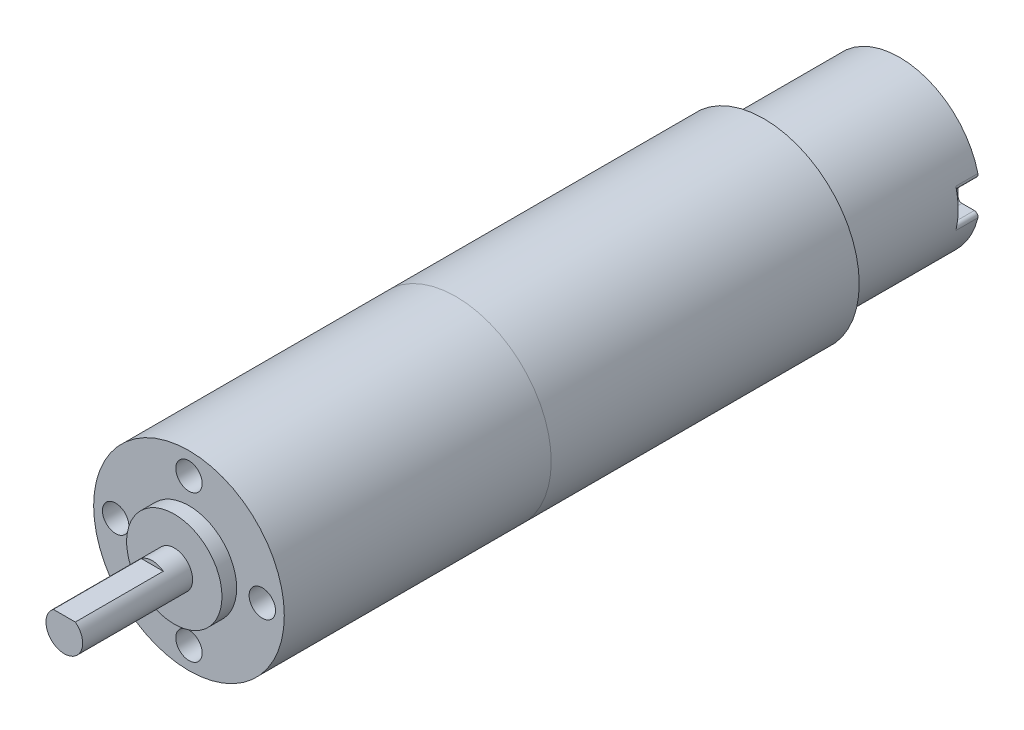
from build123d import *

# Parameters (mm, degrees)
ESQUISSE1_R                = 13
BOSS_EXTRU_REDUCTEUR_DEPTH = 36.4
ESQUISSE2_R                = 2.5
BOSS_EXTRU_ARBRE_DEPTH     = 17
ESQUISSE4_R                = 6.5
ESQUISSE4_R_2              = 2.5
BOSS_EXTRU_3_DEPTH         = 2
ESQUISSE5_R                = 1.8
ENL_V_MAT_EXTRU_2_DEPTH    = 4
ENL_V_START                = -12
ENL_V_MAT_EXTRU_3_DEPTH    = 12
ESQUISSE7_R                = 2.496805343
BOSS_EXTRU_4_DEPTH         = 3
ESQUISSE9_R                = 13
BOSS_EXTRU_5_DEPTH         = 42
ESQUISSE10_R               = 11
BOSS_EXTRU_6_DEPTH         = 18.5
ENL_V_MAT_EXTRU_5_DEPTH    = 4
ENL_V_MAT_EXTRU_6_DEPTH    = 3
CONG_1_R                   = 0.5


with BuildPart() as part:
    # Esquisse1 → Boss.-Extru. Reducteur (new body)
    with BuildSketch(Plane.XY):
        Circle(ESQUISSE1_R)
    extrude(amount=BOSS_EXTRU_REDUCTEUR_DEPTH)

    # Esquisse2 → Boss.-Extru. Arbre (add)
    with BuildSketch(Plane.XY.offset(36.4)):
        Circle(ESQUISSE2_R)
    extrude(amount=BOSS_EXTRU_ARBRE_DEPTH)

    # Esquisse4 → Boss.-Extru.3 (add)
    with BuildSketch(Plane.XY.offset(36.4)):
        Circle(ESQUISSE4_R)
        Circle(ESQUISSE4_R_2, mode=Mode.SUBTRACT)
    extrude(amount=BOSS_EXTRU_3_DEPTH)

    # Esquisse5 → Enl_v. mat.-Extru.2 (cut)
    with BuildSketch(Plane.XY.offset(36.4)):
        with Locations((0, 10)):
            Circle(ESQUISSE5_R)
        with Locations((-10, 0)):
            Circle(ESQUISSE5_R)
        with Locations((0, -10)):
            Circle(ESQUISSE5_R)
        with Locations((10, 0)):
            Circle(ESQUISSE5_R)
    extrude(amount=-ENL_V_MAT_EXTRU_2_DEPTH, mode=Mode.SUBTRACT)

    # Esquisse6 → Enl_v. mat.-Extru.3 (cut)
    with BuildSketch(Plane.XY.offset(53.4).offset(ENL_V_START)):
        with BuildLine():
            Line((0, 2), (1.5, 2))
            ThreePointArc((1.5, 2), (0, 2.5), (-1.5, 2))
            Line((-1.5, 2), (0, 2))
        make_face()
    extrude(amount=ENL_V_MAT_EXTRU_3_DEPTH, mode=Mode.SUBTRACT)


with BuildPart() as body_2:
    # Esquisse7 → Boss.-Extru.4 (new body)
    with BuildSketch(Plane.XY.offset(36.4)):
        Circle(ESQUISSE7_R)
    extrude(amount=BOSS_EXTRU_4_DEPTH)


with BuildPart() as body_3:
    # Esquisse9 → Boss.-Extru.5 (new body)
    with BuildSketch(Plane(origin=(0, 0, 0), x_dir=(-1, 0, 0), z_dir=(0, 0, -1))):
        Circle(ESQUISSE9_R)
    extrude(amount=BOSS_EXTRU_5_DEPTH)

    # Esquisse10 → Boss.-Extru.6 (add)
    with BuildSketch(Plane(origin=(0, 0, -42), x_dir=(-1, 0, 0), z_dir=(0, 0, -1))):
        Circle(ESQUISSE10_R)
    extrude(amount=BOSS_EXTRU_6_DEPTH)

    # Esquisse12 → Enl_v. mat.-Extru.5 (cut)
    with BuildSketch(Plane(origin=(0, 0, -60.5), x_dir=(-1, 0, 0), z_dir=(0, 0, -1))):
        with BuildLine():
            Line((7.549834435, -8), (0, -8))
            Line((0, -8), (-7.549834435, -8))
            ThreePointArc((-7.549834435, -8), (0, -11), (7.549834435, -8))
        make_face()
    extrude(amount=-ENL_V_MAT_EXTRU_5_DEPTH, mode=Mode.SUBTRACT)

    # Esquisse12_4 → Enl_v. mat.-Extru.6 (cut)
    with BuildSketch(Plane(origin=(0, 0, -60.5), x_dir=(-1, 0, 0), z_dir=(0, 0, -1))):
        with BuildLine():
            ThreePointArc((-10.816653826, 2), (-11, 0), (-10.816653826, -2))
            Line((-10.816653826, -2), (-8, -2))
            Line((-8, -2), (-8, 0))
            Line((-8, 0), (-8, 2))
            Line((-8, 2), (-10.816653826, 2))
        make_face()
    enl_v_mat_extru_6 = extrude(amount=-ENL_V_MAT_EXTRU_6_DEPTH, mode=Mode.SUBTRACT)

    # Sym_trie1: Enl_v. mat.-Extru.6 across plane
    add(enl_v_mat_extru_6.mirror(Plane(origin=(0, 0, 0), x_dir=(0, 0, 1), z_dir=(1, 0, 0))), mode=Mode.SUBTRACT)

    # Cong_1
    cong_1_edges = [body_3.edges().sort_by_distance(p)[0] for p in [
        (7.549834435, -8, -58.5),
        (-7.549834435, -8, -58.5),
        (-10.816653826, 2, -59),
        (-10.816653826, -2, -59),
        (-8, 2, -59),
        (-8, -2, -59),
        (8, -2, -59),
        (8, 2, -59),
        (10.816653826, -2, -59),
        (10.816653826, 2, -59),
    ]]
    fillet(cong_1_edges, radius=CONG_1_R)


solid = Compound([part.part, body_2.part, body_3.part])
